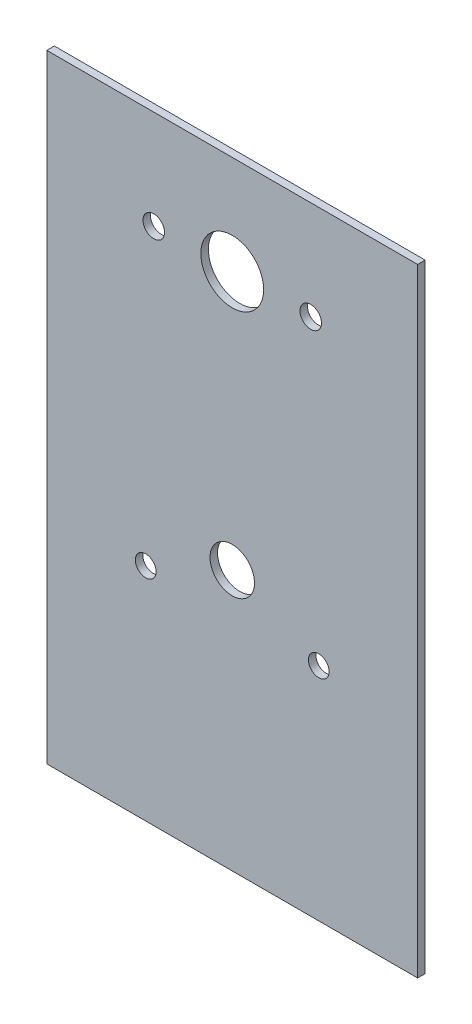
from build123d import *

# Parameters (mm, degrees)
SKETCH1_W           = 75
SKETCH1_H           = 125
SKETCH1_R           = 4.5
SKETCH1_R_2         = 6.35
SKETCH1_R_3         = 2.1
SKETCH1_R_4         = 2.1828125
BOSS_EXTRUDE1_DEPTH = 1.524


with BuildPart() as part:
    # Sketch1 → Boss-Extrude1 (new body)
    with BuildSketch(Plane.XY):
        with Locations((0, -42.5)):
            Rectangle(SKETCH1_W, SKETCH1_H)
        with Locations((0, -52.299124508)):
            Circle(SKETCH1_R, mode=Mode.SUBTRACT)
        Circle(SKETCH1_R_2, mode=Mode.SUBTRACT)
        with Locations((-17.5, -60.299124508)):
            Circle(SKETCH1_R_3, mode=Mode.SUBTRACT)
        with Locations((17.5, -60.299124508)):
            Circle(SKETCH1_R_3, mode=Mode.SUBTRACT)
        with Locations((-15.875, 0)):
            Circle(SKETCH1_R_4, mode=Mode.SUBTRACT)
        with Locations((15.875, 0)):
            Circle(SKETCH1_R_4, mode=Mode.SUBTRACT)
    extrude(amount=BOSS_EXTRUDE1_DEPTH)


solid = part.part
